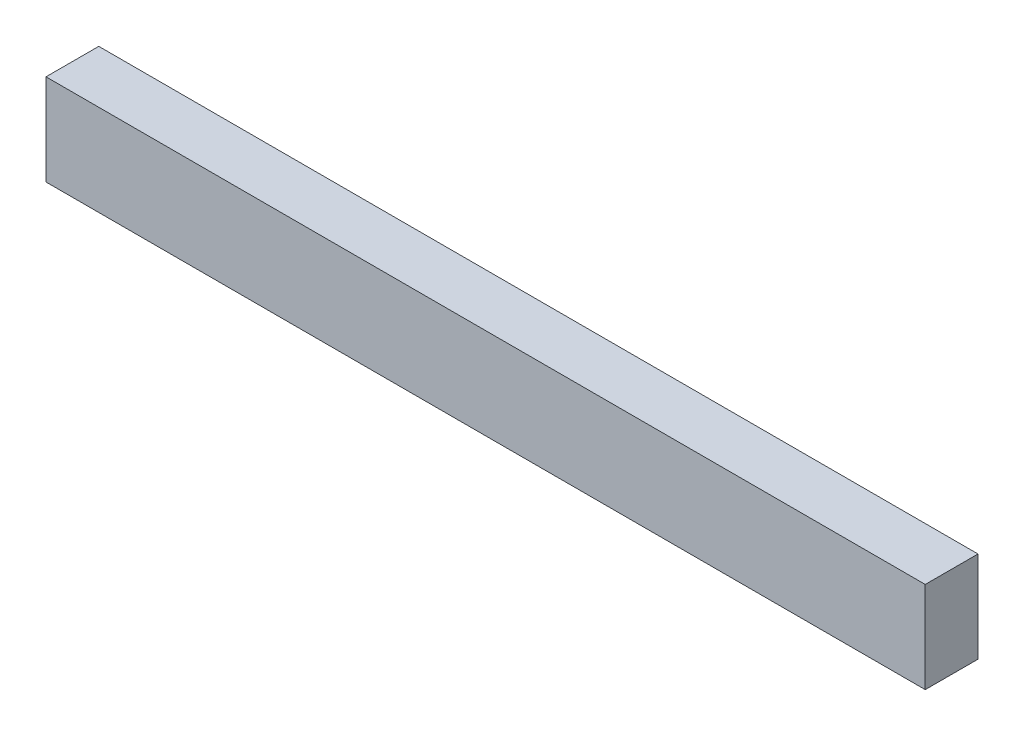
from build123d import *

# Parameters (mm, degrees)
SKETCH1_W           = 126.98901212
SKETCH1_H           = 13.162198744
BOSS_EXTRUDE1_DEPTH = 7.62
SKETCH2_R           = 4.3688
CUT_EXTRUDE1_DEPTH  = 4.318


with BuildPart() as part:
    # Sketch1 → Boss-Extrude1 (new body)
    with BuildSketch(Plane.XY):
        Rectangle(SKETCH1_W, SKETCH1_H)
    extrude(amount=BOSS_EXTRUDE1_DEPTH)

    # Sketch2 → Cut-Extrude1 (cut)
    with BuildSketch(Plane(origin=(0, 0, 0), x_dir=(-1, 0, 0), z_dir=(0, 0, -1))):
        with Locations((52.024946461, 0)):
            Circle(SKETCH2_R)
    extrude(amount=-CUT_EXTRUDE1_DEPTH, mode=Mode.SUBTRACT)


solid = part.part
